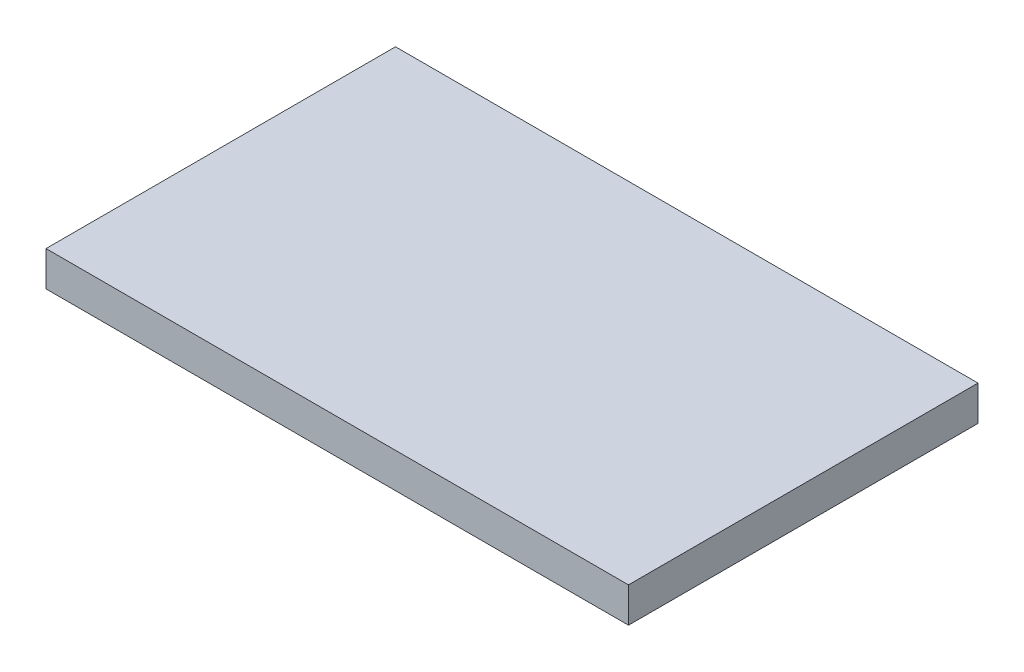
from build123d import *

# Parameters (mm, degrees)
SKETCH1_W           = 50
SKETCH1_H           = 30
BOSS_EXTRUDE1_DEPTH = 3


with BuildPart() as part:
    # Sketch1 → Boss-Extrude1 (new body)
    with BuildSketch(Plane(origin=(0, 0, 0), x_dir=(1, 0, 0), z_dir=(0, 1, 0))):
        Rectangle(SKETCH1_W, SKETCH1_H)
    extrude(amount=BOSS_EXTRUDE1_DEPTH)


solid = part.part
